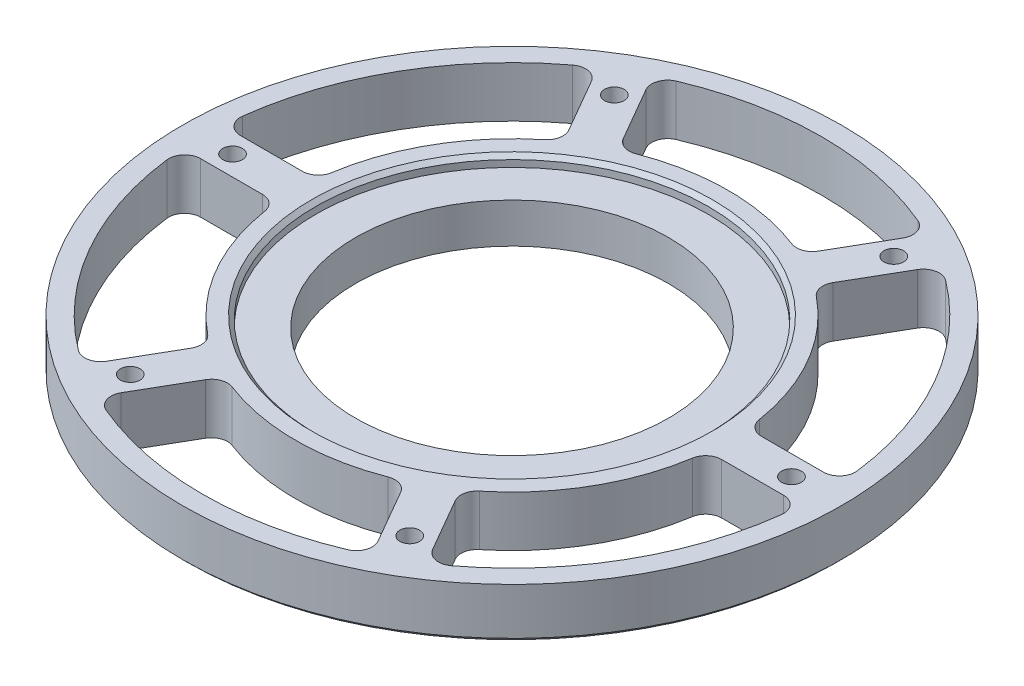
from build123d import *

# Parameters (mm, degrees)
F_10_0_1935_DIAMETER_HOLE1_D = 4.9149
CIRPATTERN3_COUNT            = 6
CUT_EXTRUDE1_DEPTH           = 13.7
FILLET1_R                    = 4
CIRPATTERN4_COUNT            = 6
FILLET1_OF_CIRPATTERN4_R     = 4
CHAMFER1_SIZE                = 1
CHAMFER2_SIZE                = 1


with BuildPart() as part:
    # Sketch2 → Revolve1 (revolve)
    with BuildSketch(Plane(origin=(0, 0, 0), x_dir=(0, 0, -1), z_dir=(1, 0, 0))):
        Polygon((-39.2125, 0), (-82.55, 0), (-82.55, 12.7), (-49.2125, 12.7), (-49.2125, 10), (-39.2125, 10), align=None)
    revolve(axis=Axis((0, -0.635, 0), (0, 1, 0)))

    # #10 (0.1935) Diameter Hole1 (through all)
    with Locations(Plane(origin=(0, 12.7, 0), x_dir=(1, 0, 0), z_dir=(0, 1, 0))):
        with Locations((-35, 60.621778)):
            f_10_0_1935_diameter_hole1 = Hole(F_10_0_1935_DIAMETER_HOLE1_D / 2)

    # CirPattern3: #10 (0.1935) Diameter Hole1 ×6 about axis
    cirpattern3_axis = Axis((0, 0, 0), (0, 1, 0))
    for i in range(1, CIRPATTERN3_COUNT):
        add(f_10_0_1935_diameter_hole1.rotate(cirpattern3_axis, i * 360 / CIRPATTERN3_COUNT), mode=Mode.SUBTRACT)

    # Sketch8 → Cut-Extrude1 (cut, through all)
    with BuildSketch(Plane(origin=(0, 12.7, 0), x_dir=(1, 0, 0), z_dir=(0, 1, 0))):
        with BuildLine():
            Line((-34.364196, 69.520533), (-22.66059, 49.249293))
            ThreePointArc((-22.66059, 49.249293), (0, 54.2125), (22.66059, 49.249293))
            Line((22.66059, 49.249293), (34.364196, 69.520533))
            ThreePointArc((34.364196, 69.520533), (0, 77.55), (-34.364196, 69.520533))
        make_face()
    cut_extrude1 = extrude(amount=-CUT_EXTRUDE1_DEPTH, mode=Mode.SUBTRACT)

    # Fillet1
    fillet1_edges = [part.edges().sort_by_distance(p)[0] for p in [
        (22.66059, 6.35, -49.249293),
        (-22.66059, 6.35, -49.249293),
        (-34.364196, 6.35, -69.520533),
        (34.364196, 6.35, -69.520533),
    ]]
    fillet(fillet1_edges, radius=FILLET1_R)

    # CirPattern4: Cut-Extrude1 ×6 about axis
    cirpattern4_axis = Axis((0, 0, 0), (0, 1, 0))
    for i in range(1, CIRPATTERN4_COUNT):
        add(cut_extrude1.rotate(cirpattern4_axis, i * 360 / CIRPATTERN4_COUNT), mode=Mode.SUBTRACT)

    # Fillet1 of CirPattern4
    fillet1_of_cirpattern4_edges = [part.edges().sort_by_distance(p)[0] for p in [
        (-31.320844, 6.35, -44.249293),
        (-53.981433, 6.35, -5),
        (-77.388646, 6.35, -5),
        (-43.02445, 6.35, -64.520533),
        (-53.981433, 6.35, 5),
        (-31.320844, 6.35, 44.249293),
        (-43.02445, 6.35, 64.520533),
        (-77.388646, 6.35, 5),
        (-22.66059, 6.35, 49.249293),
        (22.66059, 6.35, 49.249293),
        (34.364196, 6.35, 69.520533),
        (-34.364196, 6.35, 69.520533),
        (31.320844, 6.35, 44.249293),
        (53.981433, 6.35, 5),
        (77.388646, 6.35, 5),
        (43.02445, 6.35, 64.520533),
        (53.981433, 6.35, -5),
        (31.320844, 6.35, -44.249293),
        (43.02445, 6.35, -64.520533),
        (77.388646, 6.35, -5),
    ]]
    fillet(fillet1_of_cirpattern4_edges, radius=FILLET1_OF_CIRPATTERN4_R)

    # Chamfer1
    chamfer1_edges = [part.edges().sort_by_distance(p)[0] for p in [
        (0, 12.7, -49.2125),
    ]]
    chamfer(chamfer1_edges, length=CHAMFER1_SIZE)

    # Chamfer2
    chamfer2_edges = [part.edges().sort_by_distance(p)[0] for p in [
        (0, 0, -82.55),
    ]]
    chamfer(chamfer2_edges, length=CHAMFER2_SIZE)


solid = part.part
